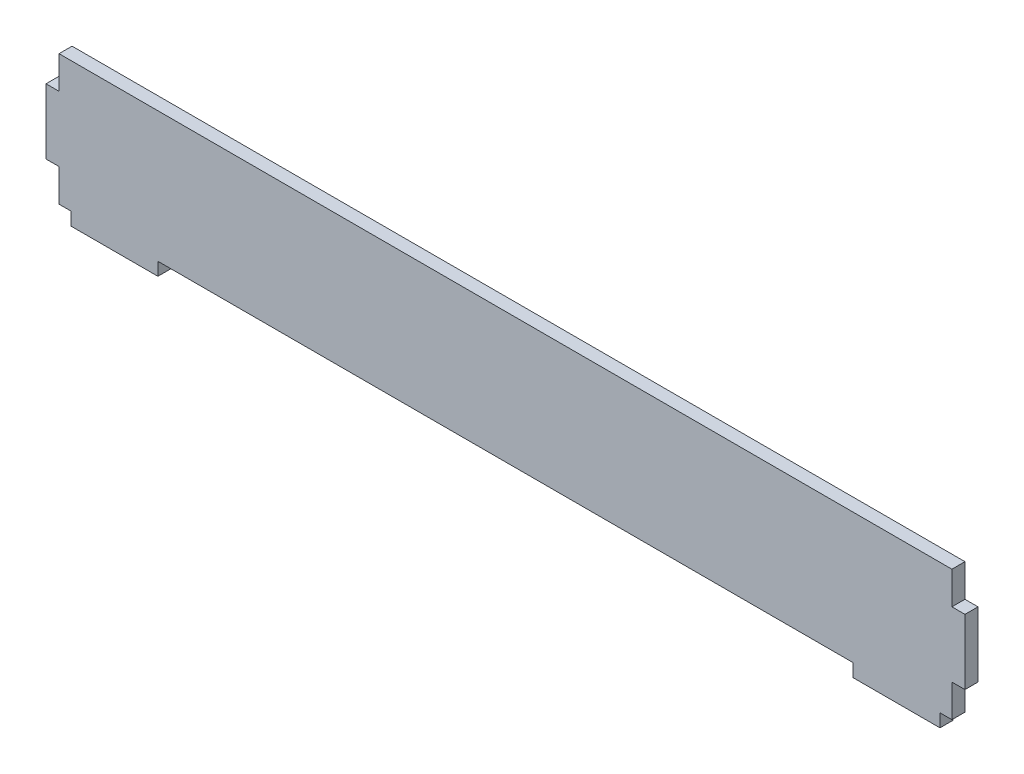
from build123d import *

# Parameters (mm, degrees)
EXTRUDE_1_DEPTH = 3


with BuildPart() as part:
    # 草图1 → 凸台-拉伸1 (new body)
    with BuildSketch(Plane.XY):
        Polygon((20, 0), (180, 0), (180, -3), (200, -3), (200, 0), (202.75, 0), (202.75, 7.5), (205.75, 7.5), (205.75, 22.5), (202.75, 22.5), (202.75, 30), (200, 30), (0, 30), (-2.75, 30), (-2.75, 22.5), (-5.75, 22.5), (-5.75, 7.5), (-2.75, 7.5), (-2.75, 0), (0, 0), (0, -3), (20, -3), align=None)
    extrude(amount=EXTRUDE_1_DEPTH)


solid = part.part
